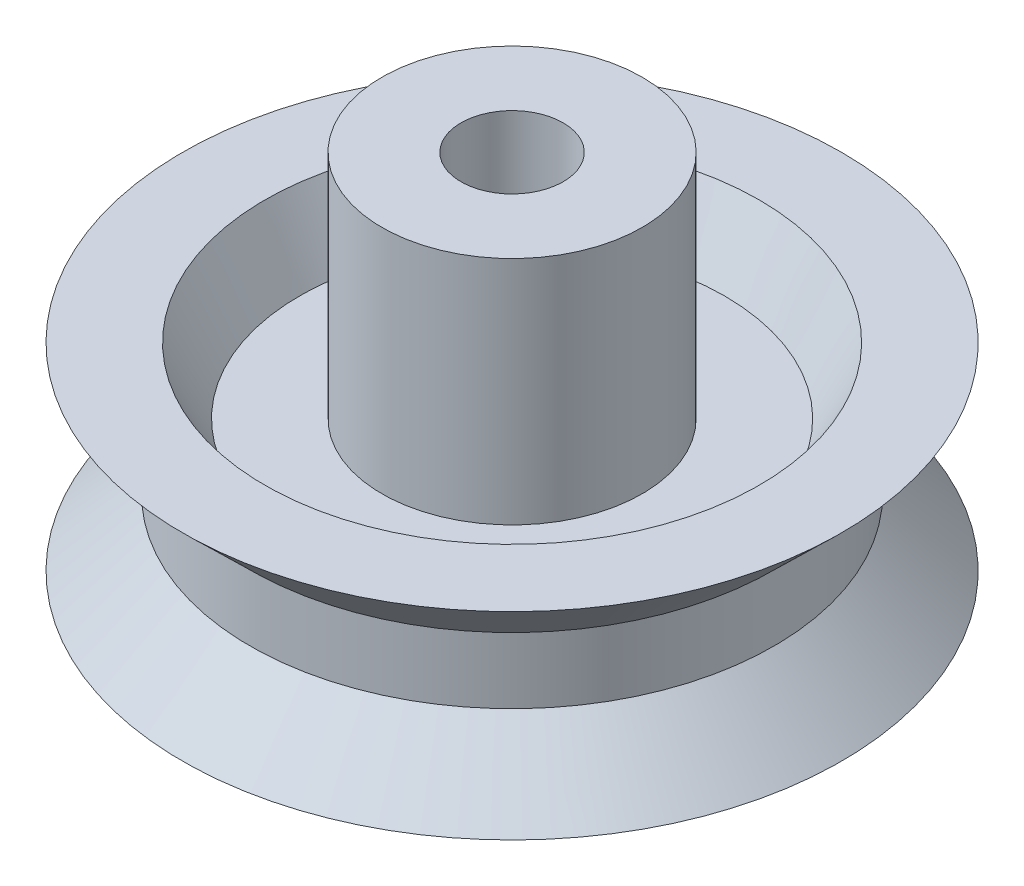
from build123d import *


with BuildPart() as part:
    # Esquisse2 → Révolution1 (revolve)
    with BuildSketch(Plane(origin=(0, 0, 0), x_dir=(0, 0, -1), z_dir=(1, 0, 0))):
        Polygon((1.55, 0), (3.95, 0), (3.95, 2), (6.45, 2), (7.5, 0), (10, 0), (7.95, 2), (7.95, 4), (10, 6), (7.5, 6), (6.45, 4), (3.95, 4), (3.95, 11), (1.55, 11), align=None)
    revolve(axis=Axis((0, -10.35463065, 0), (0, 1, 0)))


solid = part.part
